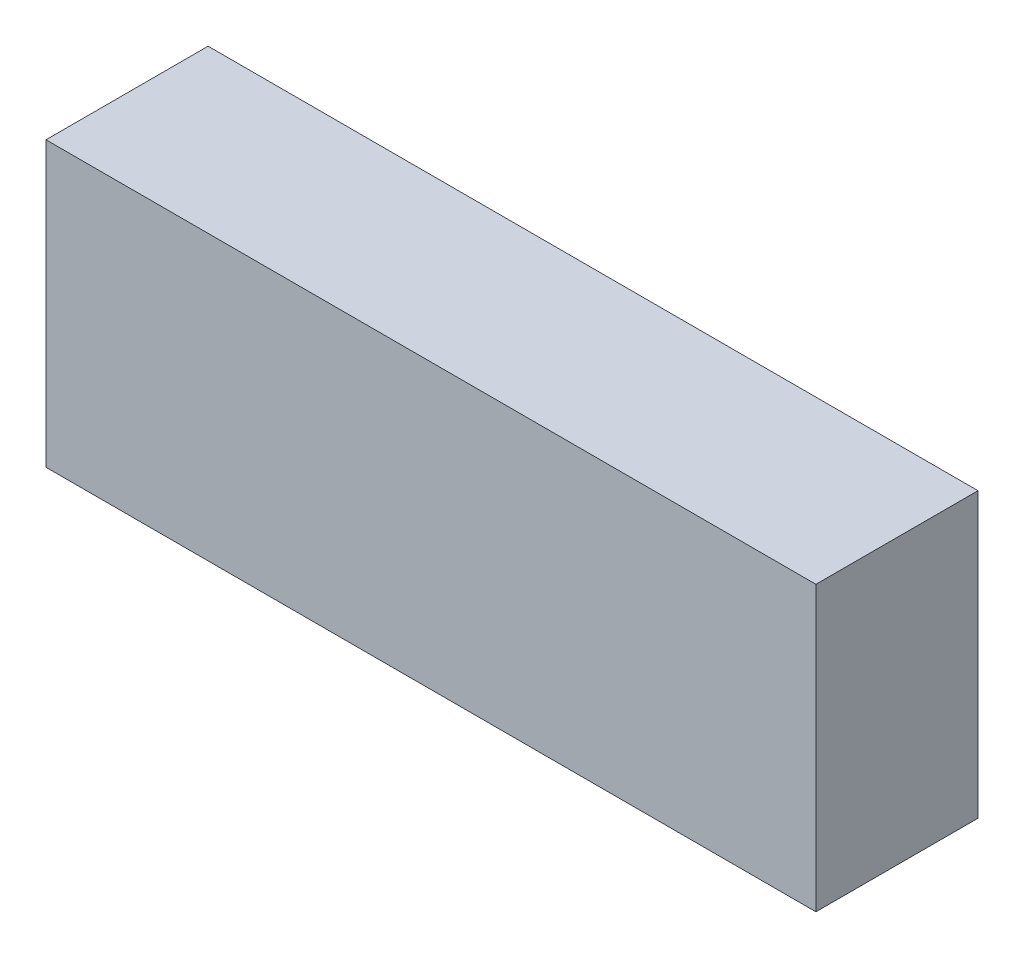
from build123d import *

# Parameters (mm, degrees)
SKETCH1_W           = 38
SKETCH1_H           = 14
BOSS_EXTRUDE1_DEPTH = 8


with BuildPart() as part:
    # Sketch1 → Boss-Extrude1 (new body)
    with BuildSketch(Plane.XY):
        Rectangle(SKETCH1_W, SKETCH1_H)
    extrude(amount=BOSS_EXTRUDE1_DEPTH)


solid = part.part
